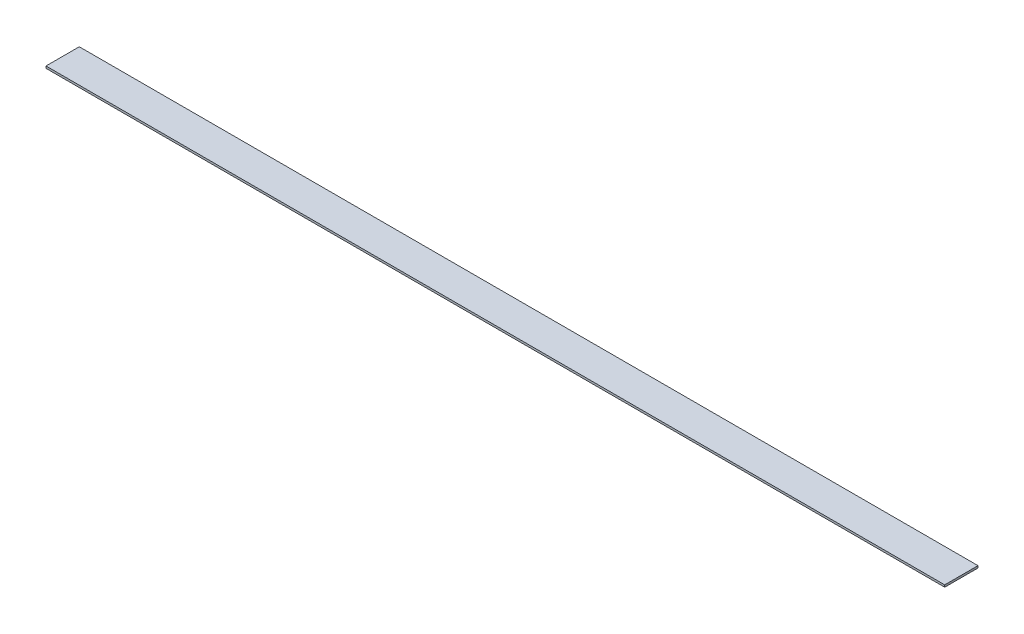
from build123d import *

# Parameters (mm, degrees)
SKETCH1_W           = 685.8
SKETCH1_H           = 25.4
BOSS_EXTRUDE1_DEPTH = 1.5875


with BuildPart() as part:
    # Sketch1 → Boss-Extrude1 (new body)
    with BuildSketch(Plane(origin=(0, 0, 0), x_dir=(1, 0, 0), z_dir=(0, 1, 0))):
        Rectangle(SKETCH1_W, SKETCH1_H)
    extrude(amount=BOSS_EXTRUDE1_DEPTH)


solid = part.part
